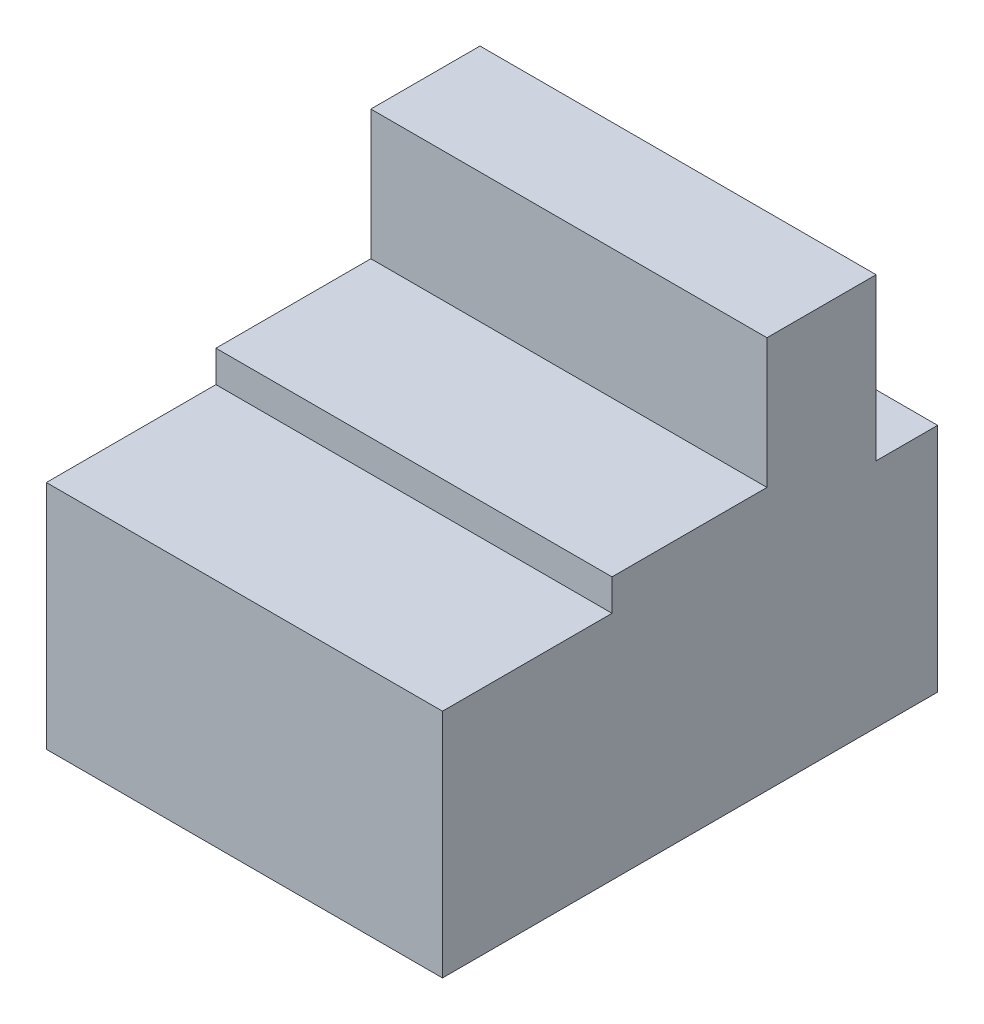
from build123d import *

# Parameters (mm, degrees)
SKETCH1_W           = 152.4
SKETCH1_H           = 190.5
BOSS_EXTRUDE1_DEPTH = 88.9
BOSS_EXTRUDE2_DEPTH = 152.4


with BuildPart() as part:
    # Sketch1 → Boss-Extrude1 (new body)
    with BuildSketch(Plane(origin=(0, 0, 0), x_dir=(1, 0, 0), z_dir=(0, 1, 0))):
        with Locations((76.2, 95.25)):
            Rectangle(SKETCH1_W, SKETCH1_H)
    extrude(amount=BOSS_EXTRUDE1_DEPTH)

    # Sketch2 → Boss-Extrude2 (add)
    with BuildSketch(Plane(origin=(0, 0, 0), x_dir=(0, 0, -1), z_dir=(1, 0, 0))):
        Polygon((65.22974, 88.9), (166.82974, 88.9), (166.82974, 150.92172), (124.83338, 150.92172), (124.83338, 101.0412), (65.22974, 101.0412), align=None)
    extrude(amount=BOSS_EXTRUDE2_DEPTH)


solid = part.part
